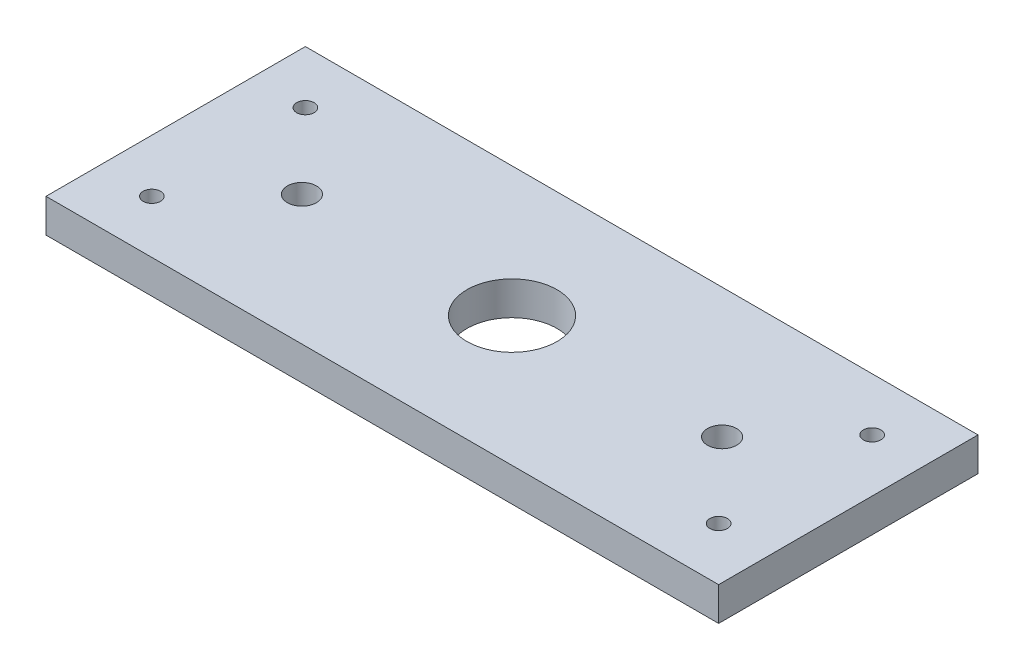
from build123d import *

# Parameters (mm, degrees)
SKETCH1_W           = 127.06755
SKETCH1_H           = 49
SKETCH1_R           = 8.5
SKETCH1_R_2         = 2.75
SKETCH1_R_3         = 1.65
BOSS_EXTRUDE1_DEPTH = 6.35


with BuildPart() as part:
    # Sketch1 → Boss-Extrude1 (new body)
    with BuildSketch(Plane(origin=(0, 0, 0), x_dir=(1, 0, 0), z_dir=(0, 1, 0))):
        Rectangle(SKETCH1_W, SKETCH1_H)
        Circle(SKETCH1_R, mode=Mode.SUBTRACT)
        with Locations((-39.6875, 0)):
            Circle(SKETCH1_R_2, mode=Mode.SUBTRACT)
        with Locations((-53.533775, 14.5)):
            Circle(SKETCH1_R_3, mode=Mode.SUBTRACT)
        with Locations((-53.533775, -14.5)):
            Circle(SKETCH1_R_3, mode=Mode.SUBTRACT)
        with Locations((53.533775, 14.5)):
            Circle(SKETCH1_R_3, mode=Mode.SUBTRACT)
        with Locations((39.6875, 0)):
            Circle(SKETCH1_R_2, mode=Mode.SUBTRACT)
        with Locations((53.533775, -14.5)):
            Circle(SKETCH1_R_3, mode=Mode.SUBTRACT)
    extrude(amount=BOSS_EXTRUDE1_DEPTH)


solid = part.part
